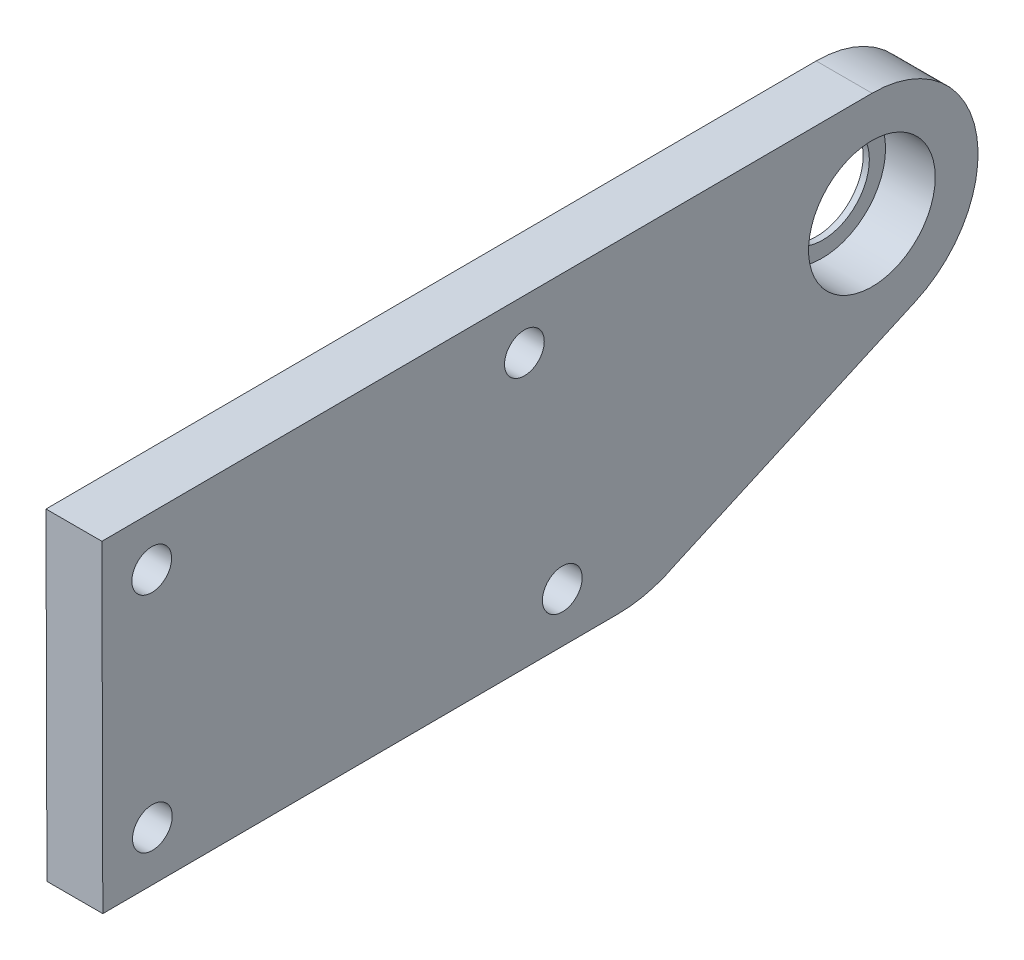
from build123d import *

# Parameters (mm, degrees)
SKETCH_1_R          = 3.75
SKETCH_1_R_2        = 1.6
EXTRUDE_1_DEPTH     = 4.5
SKETCH_2_R          = 5.1
CUT_EXTRUDE_1_DEPTH = 4


with BuildPart() as part:
    # 草图1 → 凸台-拉伸1 (new body)
    with BuildSketch(Plane(origin=(0, 0, 0), x_dir=(0, 0, -1), z_dir=(1, 0, 0))):
        with BuildLine():
            Line((-15.79768273, -16.537533957), (3.488631385, -7.878744113))
            ThreePointArc((3.488631385, -7.878744113), (8.359485225, 1.66812029), (0.014361881, 8.393204188))
            Line((0.014361881, 8.393204188), (-61.98518523, 8.15622713))
            Line((-61.98518523, 8.15622713), (-61.910470293, -17.843665517))
            Line((-61.910470293, -17.843665517), (-20.410773437, -17.685043777))
            ThreePointArc((-20.410773437, -17.685043777), (-18.035050818, -17.389387577), (-15.79768273, -16.537533957))
        make_face()
        with Locations((0.046850671, -0.106733722)):
            Circle(SKETCH_1_R, mode=Mode.SUBTRACT)
        with Locations((-57.973718038, 4.171530696)):
            Circle(SKETCH_1_R_2, mode=Mode.SUBTRACT)
        with Locations((-24.922233336, -13.702270131)):
            Circle(SKETCH_1_R_2, mode=Mode.SUBTRACT)
        with Locations((-27.973937178, 4.286197014)):
            Circle(SKETCH_1_R_2, mode=Mode.SUBTRACT)
        with Locations((-57.921992313, -13.828394983)):
            Circle(SKETCH_1_R_2, mode=Mode.SUBTRACT)
    extrude(amount=EXTRUDE_1_DEPTH)

    # 草图2 → 切除-拉伸1 (cut)
    with BuildSketch(Plane(origin=(4.5, 0, 0), x_dir=(0, 0, -1), z_dir=(1, 0, 0))):
        Circle(SKETCH_2_R)
    extrude(amount=-CUT_EXTRUDE_1_DEPTH, mode=Mode.SUBTRACT)


solid = part.part
